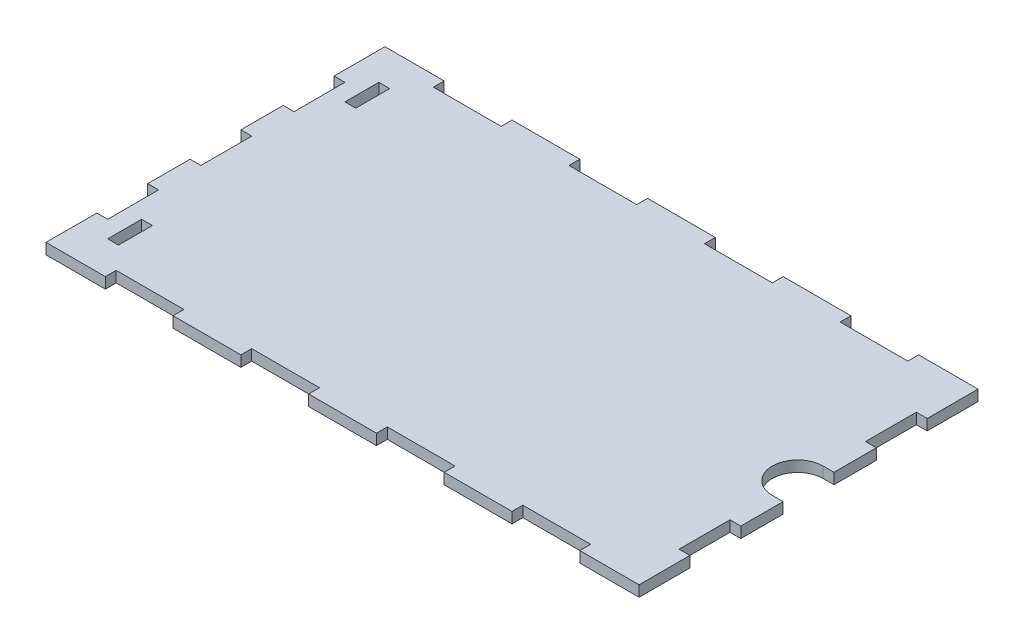
from build123d import *

# Parameters (mm, degrees)
SKETCH1_W           = 3.2
SKETCH1_H           = 10
BOSS_EXTRUDE1_DEPTH = 3.2


with BuildPart() as part:
    # Sketch1 → Boss-Extrude1 (new body)
    with BuildSketch(Plane(origin=(0, 0, 0), x_dir=(1, 0, 0), z_dir=(0, 1, 0))):
        with BuildLine():
            Line((-87.5, 7.5), (-87.5, 20))
            Line((-87.5, 20), (-84.3, 20))
            Line((-84.3, 20), (-84.3, 35))
            Line((-84.3, 35), (-87.5, 35))
            Line((-87.5, 35), (-87.5, 50))
            Line((-87.5, 50), (-70, 50))
            Line((-70, 50), (-70, 46.8))
            Line((-70, 46.8), (-50, 46.8))
            Line((-50, 46.8), (-50, 50))
            Line((-50, 50), (-30, 50))
            Line((-30, 50), (-30, 46.8))
            Line((-30, 46.8), (-10, 46.8))
            Line((-10, 46.8), (-10, 50))
            Line((-10, 50), (10, 50))
            Line((10, 50), (10, 46.8))
            Line((10, 46.8), (30, 46.8))
            Line((30, 46.8), (30, 50))
            Line((30, 50), (50, 50))
            Line((50, 50), (50, 46.8))
            Line((50, 46.8), (70, 46.8))
            Line((70, 46.8), (70, 50))
            Line((70, 50), (87.5, 50))
            Line((87.5, 50), (87.5, 35))
            Line((87.5, 35), (84.3, 35))
            Line((84.3, 35), (84.3, 20))
            Line((84.3, 20), (87.5, 20))
            Line((87.5, 20), (87.5, 7.5))
            Line((87.5, 7.5), (84.3, 7.5))
            ThreePointArc((84.3, 7.5), (76.8, 0), (84.3, -7.5))
            Line((84.3, -7.5), (87.5, -7.5))
            Line((87.5, -7.5), (87.5, -20))
            Line((87.5, -20), (84.3, -20))
            Line((84.3, -20), (84.3, -35))
            Line((84.3, -35), (87.5, -35))
            Line((87.5, -35), (87.5, -50))
            Line((87.5, -50), (70, -50))
            Line((70, -50), (70, -46.8))
            Line((70, -46.8), (50, -46.8))
            Line((50, -46.8), (50, -50))
            Line((50, -50), (30, -50))
            Line((30, -50), (30, -46.8))
            Line((30, -46.8), (10, -46.8))
            Line((10, -46.8), (10, -50))
            Line((10, -50), (-10, -50))
            Line((-10, -50), (-10, -46.8))
            Line((-10, -46.8), (-30, -46.8))
            Line((-30, -46.8), (-30, -50))
            Line((-30, -50), (-50, -50))
            Line((-50, -50), (-50, -46.8))
            Line((-50, -46.8), (-70, -46.8))
            Line((-70, -46.8), (-70, -50))
            Line((-70, -50), (-87.5, -50))
            Line((-87.5, -50), (-87.5, -35))
            Line((-87.5, -35), (-84.3, -35))
            Line((-84.3, -35), (-84.3, -20))
            Line((-84.3, -20), (-87.5, -20))
            Line((-87.5, -20), (-87.5, -7.5))
            Line((-87.5, -7.5), (-84.3, -7.5))
            Line((-84.3, -7.5), (-84.3, 7.5))
            Line((-84.3, 7.5), (-87.5, 7.5))
        make_face()
        with Locations((-77.7, 35)):
            Rectangle(SKETCH1_W, SKETCH1_H, mode=Mode.SUBTRACT)
        with Locations((-77.7, -35)):
            Rectangle(SKETCH1_W, SKETCH1_H, mode=Mode.SUBTRACT)
    extrude(amount=BOSS_EXTRUDE1_DEPTH)


solid = part.part
